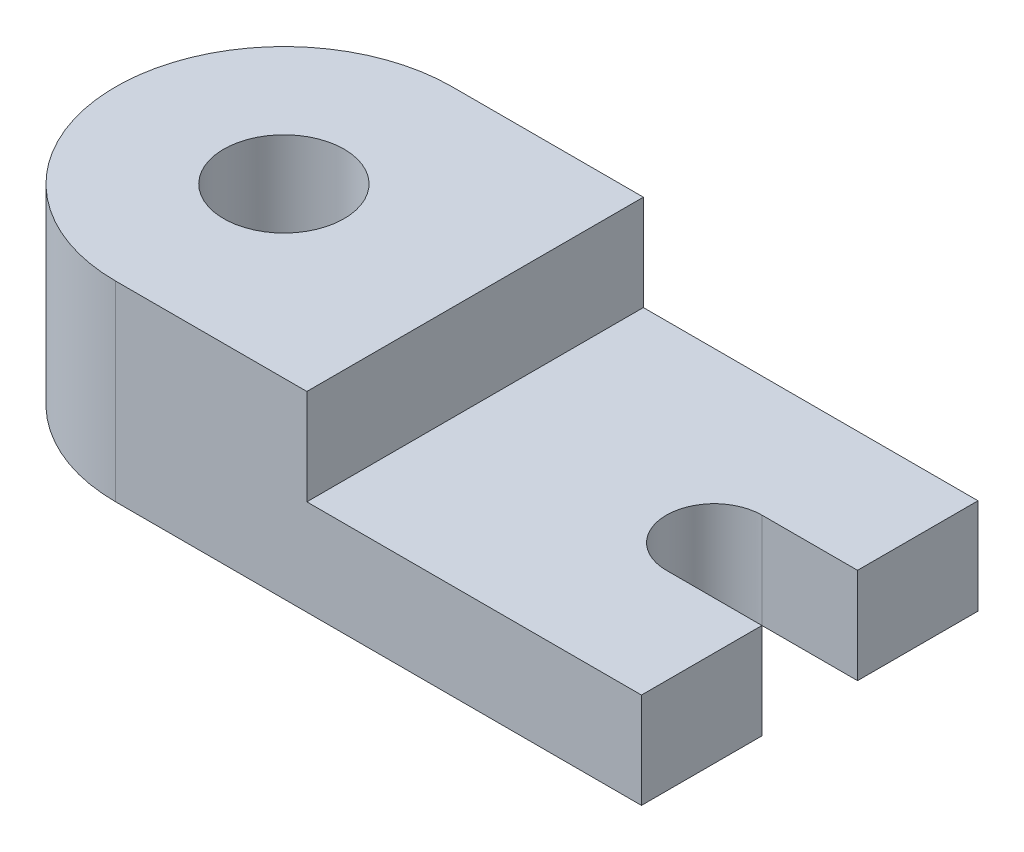
from build123d import *

# Parameters (mm, degrees)
CROQUIS1_R              = 8.001
SALIENTE_EXTRUIR1_DEPTH = 31.75
SALIENTE_EXTRUIR2_DEPTH = 12.7
CROQUIS3_W              = 47.752
CROQUIS3_H              = 44.704
CORTAR_EXTRUIR4_DEPTH   = 6.35


with BuildPart() as part:
    # Croquis1 → Saliente-Extruir1 (new body)
    with BuildSketch(Plane(origin=(0, 0, 0), x_dir=(1, 0, 0), z_dir=(0, 1, 0))):
        with BuildLine():
            Line((0, -22.352), (25.4, -22.352))
            Line((25.4, -22.352), (25.4, 22.352))
            Line((25.4, 22.352), (0, 22.352))
            ThreePointArc((0, 22.352), (-22.352, 0), (0, -22.352))
        make_face()
        Circle(CROQUIS1_R, mode=Mode.SUBTRACT)
    extrude(amount=SALIENTE_EXTRUIR1_DEPTH)

    # Croquis1_3 → Saliente-Extruir2 (add)
    with BuildSketch(Plane(origin=(0, 0, 0), x_dir=(1, 0, 0), z_dir=(0, 1, 0))):
        with BuildLine():
            Line((69.85, -22.352), (69.85, -6.35))
            Line((69.85, -6.35), (57.15, -6.35))
            ThreePointArc((57.15, -6.35), (50.8, 0), (57.15, 6.35))
            Line((57.15, 6.35), (69.85, 6.35))
            Line((69.85, 6.35), (69.85, 22.352))
            Line((69.85, 22.352), (25.4, 22.352))
            Line((25.4, 22.352), (25.4, -22.352))
            Line((25.4, -22.352), (69.85, -22.352))
        make_face()
    extrude(amount=SALIENTE_EXTRUIR2_DEPTH)

    # Croquis3 → Cortar-Extruir4 (cut)
    with BuildSketch(Plane(origin=(0, 31.75, 0), x_dir=(1, 0, 0), z_dir=(0, 1, 0))):
        with Locations((1.524, 0)):
            Rectangle(CROQUIS3_W, CROQUIS3_H)
    extrude(amount=-CORTAR_EXTRUIR4_DEPTH, mode=Mode.SUBTRACT)


solid = part.part
